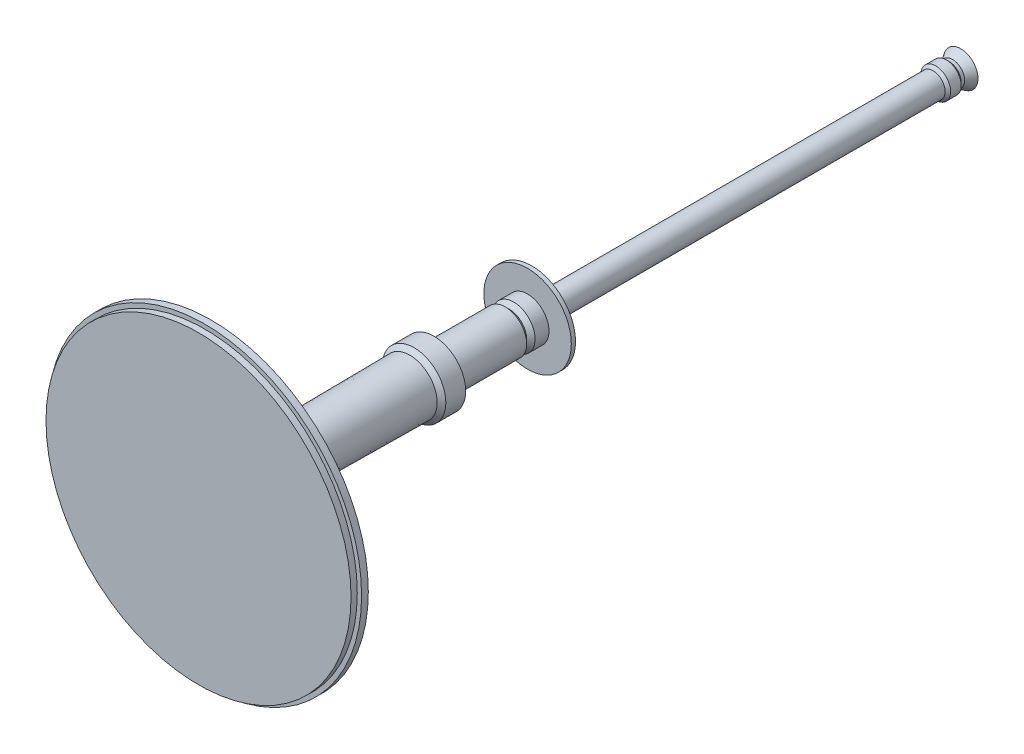
from build123d import *


with BuildPart() as part:
    # Sketch12 → Revolve2 (revolve)
    with BuildSketch(Plane(origin=(0, 0, 0), x_dir=(0, 0, -1), z_dir=(1, 0, 0))):
        Polygon((996.979831822, 0), (996.979831822, 448.154362623), (1015.309498351, 448.154362623), (1015.309498351, 460.844131759), (1035.049139229, 460.844131759), (1035.049139229, 448.154362623), (1035.049139229, 438.418962309), (1049.739382804, 438.418962309), (1049.739382804, 107.862695979), (1082.4718279, 107.862695979), (1082.4718279, 93.31637014), (1090.933076859, 84.855121181), (1156.280143072, 84.855121181), (1156.280143072, 76.411453441), (1617.589293356, 80.633287311), (1630.272376185, 93.31637014), (1688.665257097, 93.31637014), (1688.665257097, 62.954107013), (1898.216315919, 62.954107013), (1910.575471981, 50.594950951), (1922.934628043, 62.954107013), (1950.934428364, 62.954107013), (1963.792504571, 62.954107013), (1963.792504571, 116.171139603), (1963.792504571, 128.530295665), (1976.151660632, 128.530295665), (1976.151660632, 93.31637014), (1983.424823552, 100.58953306), (1983.424823552, 35.664179648), (3155.097212513, 35.664179648), (3163.146026729, 43.712993865), (3194.167030322, 43.712993865), (3202.215844538, 35.664179648), (3212.399611966, 35.664179648), (3236.709720825, 50.594950951), (3236.709720825, 0), align=None)
    revolve(axis=Axis((0, 0, 0), (0, 0, -1)))


solid = part.part
